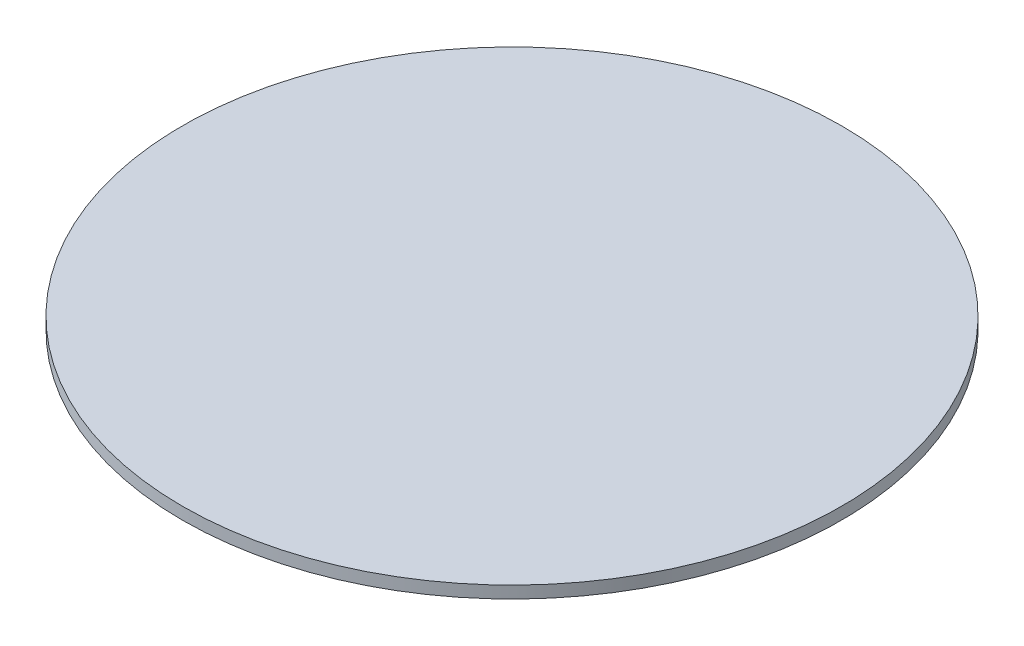
from build123d import *

# Parameters (mm, degrees)
SKETCH1_R           = 2076.2
BOSS_EXTRUDE1_DEPTH = 76.2


with BuildPart() as part:
    # Sketch1 → Boss-Extrude1 (new body)
    with BuildSketch(Plane(origin=(0, 0, 0), x_dir=(1, 0, 0), z_dir=(0, 1, 0))):
        Circle(SKETCH1_R)
    extrude(amount=BOSS_EXTRUDE1_DEPTH)


solid = part.part
